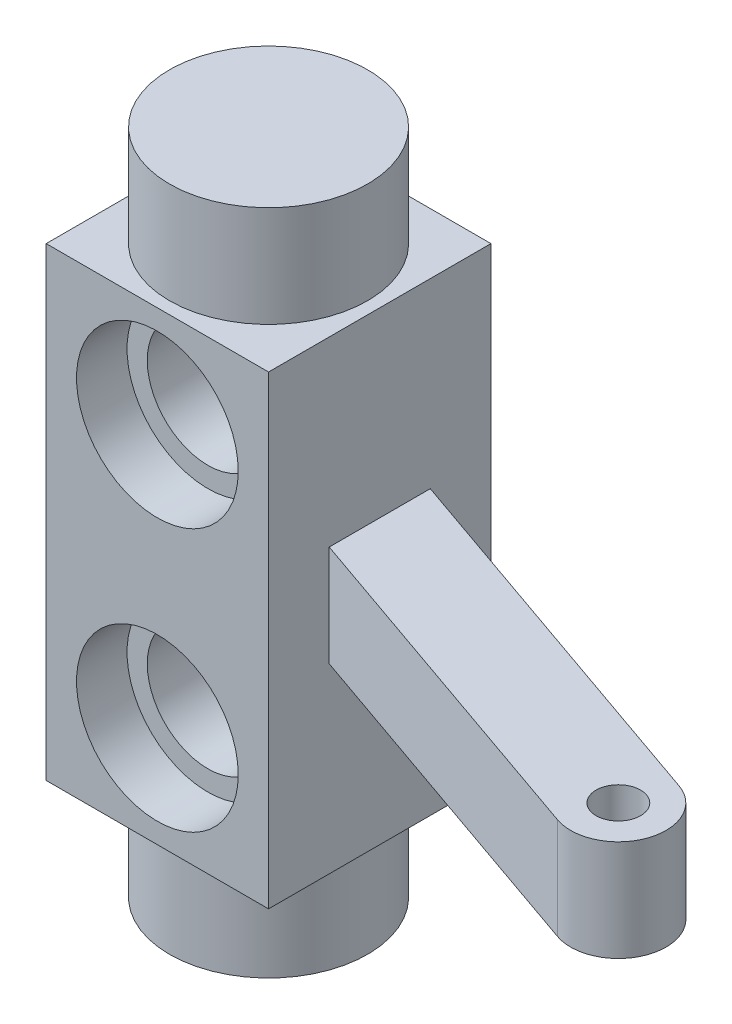
from build123d import *

# Parameters (mm, degrees)
SKETCH1_R           = 4.9
BOSS_EXTRUDE1_DEPTH = 5
SKETCH2_W           = 11
SKETCH2_H           = 11
BOSS_EXTRUDE2_DEPTH = 23
SKETCH3_R           = 4
CUT_EXTRUDE1_DEPTH  = 2.5
SKETCH4_R           = 4
CUT_EXTRUDE2_DEPTH  = 2.5
SKETCH5_R           = 3
CUT_EXTRUDE3_DEPTH  = 6
SKETCH6_R           = 4.9
BOSS_EXTRUDE3_DEPTH = 5
SKETCH7_R           = 1.1
BOSS_EXTRUDE4_DEPTH = 2.5


with BuildPart() as part:
    # Sketch1 → Boss-Extrude1 (new body)
    with BuildSketch(Plane(origin=(0, 0, 0), x_dir=(1, 0, 0), z_dir=(0, 1, 0))):
        Circle(SKETCH1_R)
    extrude(amount=BOSS_EXTRUDE1_DEPTH)

    # Sketch2 → Boss-Extrude2 (add)
    with BuildSketch(Plane(origin=(0, 5, 0), x_dir=(1, 0, 0), z_dir=(0, 1, 0))):
        Rectangle(SKETCH2_W, SKETCH2_H)
    extrude(amount=BOSS_EXTRUDE2_DEPTH)

    # Sketch3 → Cut-Extrude1 (cut)
    with BuildSketch(Plane.XY.offset(5.5)):
        with Locations((0, 10)):
            Circle(SKETCH3_R)
    cut_extrude1 = extrude(amount=-CUT_EXTRUDE1_DEPTH, mode=Mode.SUBTRACT)

    # Sketch4 → Cut-Extrude2 (cut)
    with BuildSketch(Plane(origin=(0, 0, -5.5), x_dir=(-1, 0, 0), z_dir=(0, 0, -1))):
        with Locations((0, 10)):
            Circle(SKETCH4_R)
    cut_extrude2 = extrude(amount=-CUT_EXTRUDE2_DEPTH, mode=Mode.SUBTRACT)

    # Sketch5 → Cut-Extrude3 (cut)
    with BuildSketch(Plane(origin=(0, 0, -3), x_dir=(-1, 0, 0), z_dir=(0, 0, -1))):
        with Locations((0, 10)):
            Circle(SKETCH5_R)
    cut_extrude3 = extrude(amount=-CUT_EXTRUDE3_DEPTH, mode=Mode.SUBTRACT)

    # Sketch6 → Boss-Extrude3 (add)
    with BuildSketch(Plane(origin=(0, 28, 0), x_dir=(1, 0, 0), z_dir=(0, 1, 0))):
        Circle(SKETCH6_R)
    extrude(amount=BOSS_EXTRUDE3_DEPTH)

    # Sketch7 → Boss-Extrude4 (add, symmetric)
    with BuildSketch(Plane(origin=(0, 16.5, 0), x_dir=(1, 0, 0), z_dir=(0, 1, 0))):
        with BuildLine():
            Line((5.5, -2.5), (22.834272834, -8.537145633))
            ThreePointArc((22.834272834, -8.537145633), (25.840339287, -7.084092403), (24.387286057, -4.07802595))
            Line((24.387286057, -4.07802595), (5.5, 2.5))
            Line((5.5, 2.5), (5.5, 0))
            Line((5.5, 0), (5.5, -2.5))
        make_face()
        with Locations((23.610779446, -6.307585792)):
            Circle(SKETCH7_R, mode=Mode.SUBTRACT)
    extrude(amount=BOSS_EXTRUDE4_DEPTH, both=True)

    # Mirror1: Cut-Extrude1 across plane
    add(cut_extrude1.mirror(Plane.ZX.offset(16.5)), mode=Mode.SUBTRACT)

    # Mirror2: Cut-Extrude2 across plane
    add(cut_extrude2.mirror(Plane.ZX.offset(16.5)), mode=Mode.SUBTRACT)

    # Mirror3: Cut-Extrude3 across plane
    add(cut_extrude3.mirror(Plane.ZX.offset(16.5)), mode=Mode.SUBTRACT)


solid = part.part
